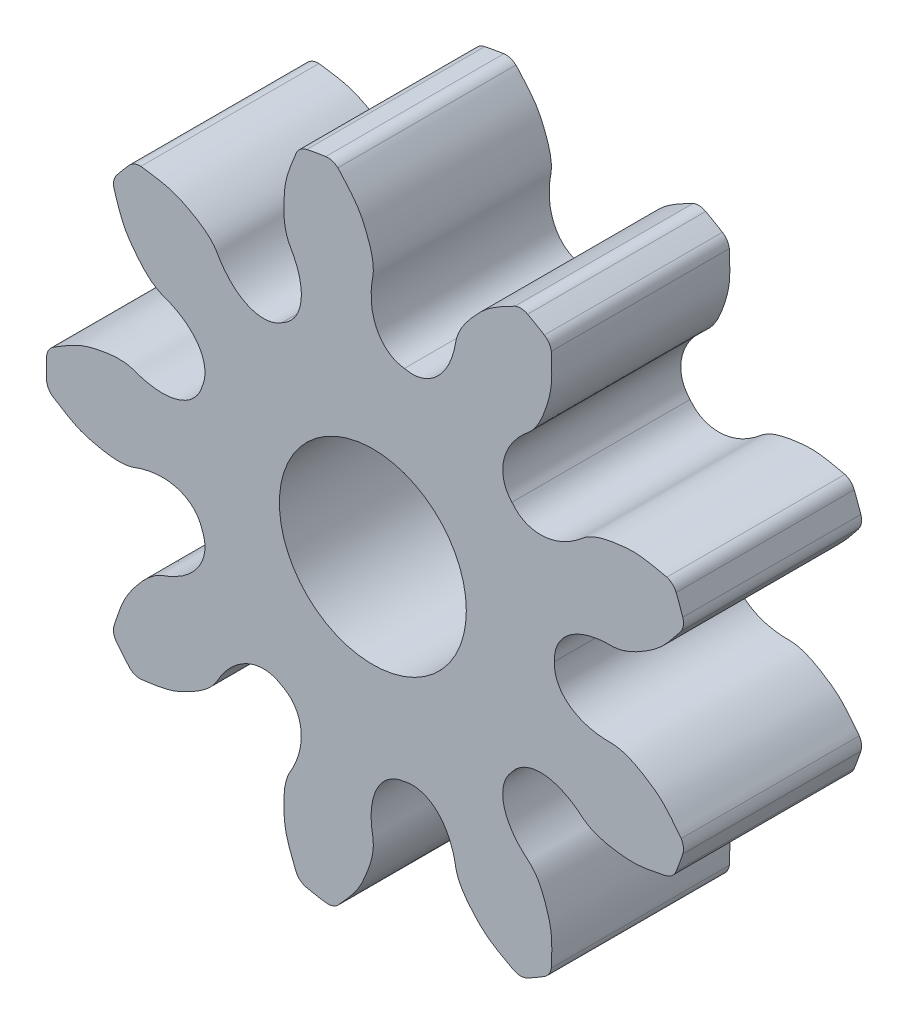
from build123d import *

# Parameters (mm, degrees)
SKETCHREVOLVESPURPINION_W       = 6
SKETCHREVOLVESPURPINION_H       = 11.000008216
TOOTHEXTRUDECUTSPURPINION_DEPTH = 3
PATTERNSPURPINION_COUNT         = 9
BOREREVOLVESKETCH_W             = 6
BOREREVOLVESKETCH_H             = 3.15
FILLET1_R                       = 0.5
FILLET2_R                       = 0.5


with BuildPart() as part:
    # SketchRevolveSpurPinion → SpurPinion (revolve)
    with BuildSketch(Plane(origin=(0, 0, 0), x_dir=(0, 0, -1), z_dir=(1, 0, 0))):
        with Locations((0, 5.500004108)):
            Rectangle(SKETCHREVOLVESPURPINION_W, SKETCHREVOLVESPURPINION_H)
    revolve(axis=Axis((0, 0, 0), (0, 0, -1)))

    # SketchToothSpurPinion → ToothExtrudeCutSpurPinion (cut, symmetric)
    with BuildSketch(Plane.XY):
        with BuildLine():
            ThreePointArc((10.535343194, 3.516755987), (11.10680102, 0), (10.535343194, -3.516755987))
            add(Edge.make_bspline(
                [(6.120368571, 0), (6.120368571, -0.024935686), (6.119694613, -0.058317802), (6.120146447, -0.106789507), (6.121294691, -0.14538609), (6.124776378, -0.190461209), (6.130112147, -0.235258472), (6.137338143, -0.279678185), (6.146395015, -0.323627955), (6.157239522, -0.367021714), (6.169816186, -0.409781061), (6.184066415, -0.451835674), (6.199927653, -0.493123655), (6.217335176, -0.533591591), (6.236223091, -0.573194417), (6.256525435, -0.611895101), (6.278177091, -0.649664174), (6.301114583, -0.686479157), (6.325276722, -0.722323912), (6.350605109, -0.757187943), (6.377044517, -0.791065684), (6.40454313, -0.823955797), (6.433052696, -0.855860491), (6.462528566, -0.886784885), (6.492929675, -0.916736415), (6.524218444, -0.9457243), (6.556360648, -0.973759068), (6.589325235, -1.000852138), (6.623084134, -1.027015458), (6.657612033, -1.052261197), (6.692886165, -1.07660149), (6.728886079, -1.100048226), (6.765593423, -1.122612877), (6.802991731, -1.144306365), (6.841066219, -1.165138954), (6.879803598, -1.18512018), (6.919191891, -1.204258792), (6.959220269, -1.222562724), (6.999878903, -1.240039071), (7.041158822, -1.256694089), (7.083051787, -1.272533199), (7.12555018, -1.287561003), (7.168646903, -1.301781303), (7.212335282, -1.31519713), (7.25660899, -1.327810775), (7.301461974, -1.339623817), (7.346888389, -1.350637164), (7.392882544, -1.360851082), (7.43943885, -1.370265238), (7.486551779, -1.378878732), (7.534215825, -1.38669013), (7.582425469, -1.393697512), (7.631175154, -1.399898464), (7.680459257, -1.405290265), (7.73027207, -1.409869331), (7.780607773, -1.41363348), (7.831460458, -1.416573491), (7.882823963, -1.418705194), (7.934692431, -1.419948163), (7.987058159, -1.4205849), (8.242451529, -1.415455225), (8.641505085, -1.529536631), (9.210183408, -1.846463434), (9.64043495, -2.137213455), (9.932490428, -2.459216956), (10.097930751, -2.647792828), (10.321140298, -2.948068261), (10.498098088, -3.122479129), (10.535343194, -3.516755987)],
                knots=[0.502630296, 0.502630296, 0.502630296, 0.502630296, 0.508845224, 0.510950398, 0.514711403, 0.518466564, 0.522214064, 0.525952228, 0.529679563, 0.533394786, 0.537096853, 0.540784973, 0.544458619, 0.54811753, 0.551761711, 0.555391419, 0.559007156, 0.562609644, 0.566199812, 0.56977877, 0.573347788, 0.576908274, 0.580461748, 0.584009826, 0.587554193, 0.591096592, 0.594638798, 0.598182612, 0.601729839, 0.605282283, 0.60884173, 0.612409946, 0.615988666, 0.619579588, 0.623184371, 0.626804627, 0.630441922, 0.634097773, 0.637773645, 0.641470953, 0.64519106, 0.648935276, 0.652704862, 0.656501028, 0.660324935, 0.664177697, 0.668060379, 0.671974004, 0.675919549, 0.679897951, 0.683910104, 0.687956865, 0.692039054, 0.696157453, 0.700312812, 0.704505848, 0.708737245, 0.713007659, 0.717317716, 0.721668017, 0.726059134, 0.780965653, 0.821469371, 0.888944531, 0.908617215, 0.929559103, 0.951770197, 1, 1, 1, 1], degree=3))
            add(Edge.make_bspline(
                [(6.120368571, 0), (6.120368571, 0.024935686), (6.119694613, 0.058317802), (6.120146447, 0.106789507), (6.121294691, 0.14538609), (6.124776378, 0.190461209), (6.130112147, 0.235258472), (6.137338143, 0.279678185), (6.146395015, 0.323627955), (6.157239522, 0.367021714), (6.169816186, 0.409781061), (6.184066415, 0.451835674), (6.199927653, 0.493123655), (6.217335176, 0.533591591), (6.236223091, 0.573194417), (6.256525435, 0.611895101), (6.278177091, 0.649664174), (6.301114583, 0.686479157), (6.325276722, 0.722323912), (6.350605109, 0.757187943), (6.377044517, 0.791065684), (6.40454313, 0.823955797), (6.433052696, 0.855860491), (6.462528566, 0.886784885), (6.492929675, 0.916736415), (6.524218444, 0.9457243), (6.556360648, 0.973759068), (6.589325235, 1.000852138), (6.623084134, 1.027015458), (6.657612033, 1.052261197), (6.692886165, 1.07660149), (6.728886079, 1.100048226), (6.765593423, 1.122612877), (6.802991731, 1.144306365), (6.841066219, 1.165138954), (6.879803598, 1.18512018), (6.919191891, 1.204258792), (6.959220269, 1.222562724), (6.999878903, 1.240039071), (7.041158822, 1.256694089), (7.083051787, 1.272533199), (7.12555018, 1.287561003), (7.168646903, 1.301781303), (7.212335282, 1.31519713), (7.25660899, 1.327810775), (7.301461974, 1.339623817), (7.346888389, 1.350637164), (7.392882544, 1.360851082), (7.43943885, 1.370265238), (7.486551779, 1.378878732), (7.534215825, 1.38669013), (7.582425469, 1.393697512), (7.631175154, 1.399898464), (7.680459257, 1.405290265), (7.73027207, 1.409869331), (7.780607773, 1.41363348), (7.831460458, 1.416573491), (7.882823963, 1.418705194), (7.934692431, 1.419948163), (7.987058159, 1.4205849), (8.242451529, 1.415455225), (8.641505085, 1.529536631), (9.210183408, 1.846463434), (9.64043495, 2.137213455), (9.932490428, 2.459216956), (10.097930751, 2.647792828), (10.321140298, 2.948068261), (10.498098088, 3.122479129), (10.535343194, 3.516755987)],
                knots=[0.502630296, 0.502630296, 0.502630296, 0.502630296, 0.508845224, 0.510950398, 0.514711403, 0.518466564, 0.522214064, 0.525952228, 0.529679563, 0.533394786, 0.537096853, 0.540784973, 0.544458619, 0.54811753, 0.551761711, 0.555391419, 0.559007156, 0.562609644, 0.566199812, 0.56977877, 0.573347788, 0.576908274, 0.580461748, 0.584009826, 0.587554193, 0.591096592, 0.594638798, 0.598182612, 0.601729839, 0.605282283, 0.60884173, 0.612409946, 0.615988666, 0.619579588, 0.623184371, 0.626804627, 0.630441922, 0.634097773, 0.637773645, 0.641470953, 0.64519106, 0.648935276, 0.652704862, 0.656501028, 0.660324935, 0.664177697, 0.668060379, 0.671974004, 0.675919549, 0.679897951, 0.683910104, 0.687956865, 0.692039054, 0.696157453, 0.700312812, 0.704505848, 0.708737245, 0.713007659, 0.717317716, 0.721668017, 0.726059134, 0.780965653, 0.821469371, 0.888944531, 0.908617215, 0.929559103, 0.951770197, 1, 1, 1, 1], degree=3))
        make_face()
    toothextrudecutspurpinion = extrude(amount=TOOTHEXTRUDECUTSPURPINION_DEPTH, both=True, mode=Mode.SUBTRACT)

    # PatternSpurPinion: ToothExtrudeCutSpurPinion ×9 about axis
    patternspurpinion_axis = Axis((0, 0, 55), (0, 0, -1))
    for i in range(1, PATTERNSPURPINION_COUNT):
        add(toothextrudecutspurpinion.rotate(patternspurpinion_axis, i * 360 / PATTERNSPURPINION_COUNT), mode=Mode.SUBTRACT)

    # BoreRevolveSketch → BoreRevolveCut (revolve, cut)
    with BuildSketch(Plane(origin=(0, 0, 0), x_dir=(0, 0, -1), z_dir=(1, 0, 0))):
        with Locations((0, 1.575)):
            Rectangle(BOREREVOLVESKETCH_W, BOREREVOLVESKETCH_H)
    revolve(axis=Axis((0, 0, 0), (0, 0, -1)), mode=Mode.SUBTRACT)

    # Fillet1
    fillet1_edges = [part.edges().sort_by_distance(p)[0] for p in [
        (10.497721313, -3.286035299, -1.5),
        (10.497721313, 3.286035299, 1.4999997),
        (10.153943852, 4.230556109, -1.5),
        (5.929498302, 9.26505427, 1.4999997),
        (5.059023214, 9.767623297, -1.5),
        (-10.988521517, 0.502569026, 1.4999997),
        (-8.740740989, 6.67829527, 1.4999997),
        (-8.094650703, 7.44827569, 1.4999997),
        (-2.40307061, 10.734310988, -1.5),
        (-1.413202863, 10.908851379, -1.5),
    ]]
    fillet(fillet1_edges, radius=FILLET1_R)

    # Fillet2
    fillet2_edges = [part.edges().sort_by_distance(p)[0] for p in [
        (10.153943852, -4.230556109, 1.4999997),
        (5.929498302, -9.26505427, -1.5),
        (5.059023214, -9.767623297, 1.4999997),
        (-1.413202863, -10.908851379, 1.4999997),
        (-2.40307061, -10.734310988, 1.4999997),
        (-8.094650703, -7.44827569, -1.5),
        (-8.740740989, -6.67829527, -1.5),
        (-10.988521517, -0.502569026, -1.5),
    ]]
    fillet(fillet2_edges, radius=FILLET2_R)


solid = part.part
